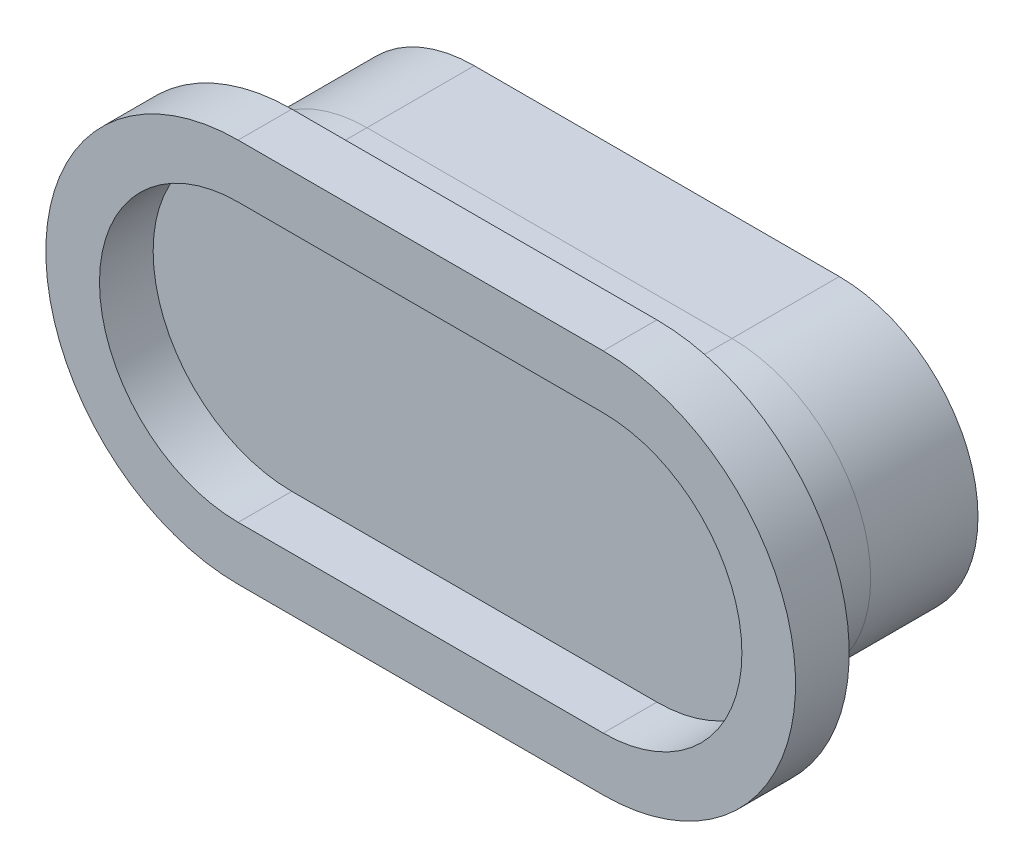
from build123d import *

# Parameters (mm, degrees)
EXTRUDE_1_DEPTH   = 20
EXTRUDE_2_DEPTH   = 14
EXTRUDE_1_2_DEPTH = 10


with BuildPart() as part:
    # 草图1 → Extrude 1 (new body)
    with BuildSketch(Plane.XY):
        with BuildLine():
            Line((0, 25.845361824), (68.028206251, 25.845361824))
            ThreePointArc((68.028206251, 25.845361824), (93.873568075, 0), (68.028206251, -25.845361824))
            Line((68.028206251, -25.845361824), (0, -25.845361824))
            ThreePointArc((0, -25.845361824), (-25.845361824, 0), (0, 25.845361824))
        make_face()
    extrude(amount=EXTRUDE_1_DEPTH)


with BuildPart() as body_2:
    # 草图6 → 凸台-拉伸2 (new body)
    with BuildSketch(Plane.XY.offset(20)):
        with BuildLine():
            Line((0, -25.845361824), (68.028206251, -25.845361824))
            ThreePointArc((68.028206251, -25.845361824), (93.873568075, 0), (68.028206251, 25.845361824))
            Line((68.028206251, 25.845361824), (0, 25.845361824))
            ThreePointArc((0, 25.845361824), (-25.845361824, 0), (0, -25.845361824))
        make_face()
    extrude(amount=EXTRUDE_2_DEPTH)


with BuildPart() as body_3:
    # 草图7 → Extrude 1 2 (new body)
    with BuildSketch(Plane.XY.offset(34)):
        with BuildLine():
            Line((68.028206251, 35.845361824), (0, 35.845361824))
            ThreePointArc((0, 35.845361824), (-35.845361824, 0), (0, -35.845361824))
            Line((0, -35.845361824), (68.028206251, -35.845361824))
            ThreePointArc((68.028206251, -35.845361824), (103.873568075, 0), (68.028206251, 35.845361824))
        make_face()
        with BuildLine():
            Line((68.028206251, 25.845361824), (0, 25.845361824))
            ThreePointArc((0, 25.845361824), (-25.845361824, 0), (0, -25.845361824))
            Line((0, -25.845361824), (68.028206251, -25.845361824))
            ThreePointArc((68.028206251, -25.845361824), (93.873568075, 0), (68.028206251, 25.845361824))
        make_face(mode=Mode.SUBTRACT)
    extrude(amount=EXTRUDE_1_2_DEPTH)


solid = Compound([part.part, body_2.part, body_3.part])
